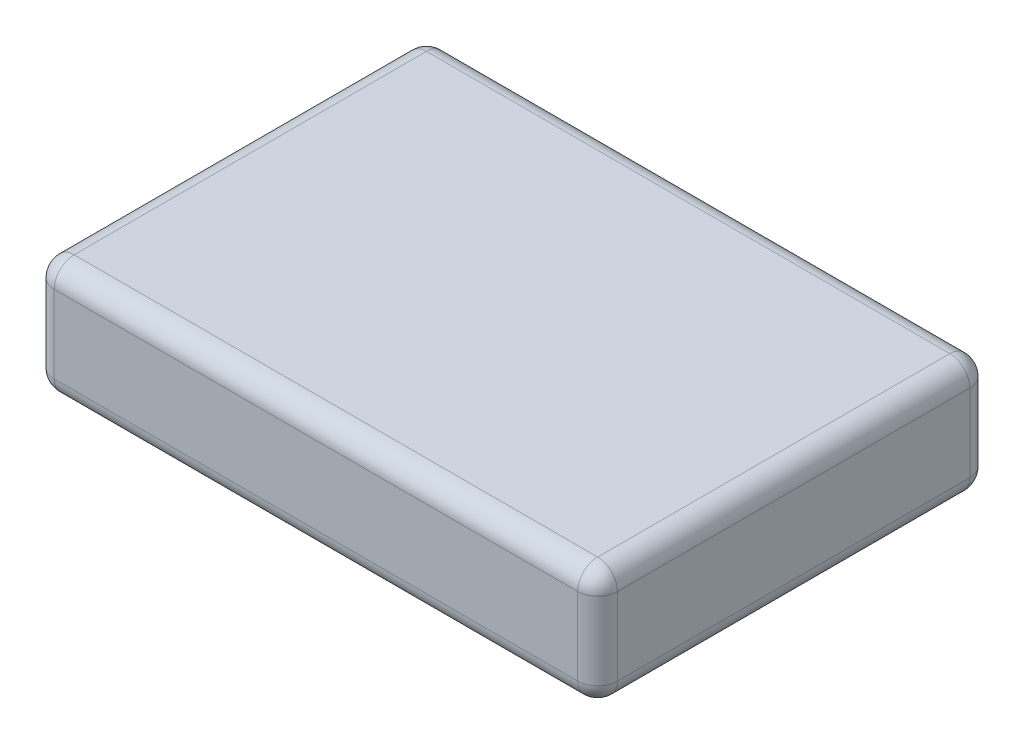
from build123d import *

# Parameters (mm, degrees)
SKETCH1_W           = 71.882
SKETCH1_H           = 50.038
BOSS_EXTRUDE1_DEPTH = 14.986
FILLET1_R           = 2.54


with BuildPart() as part:
    # Sketch1 → Boss-Extrude1 (new body)
    with BuildSketch(Plane(origin=(0, 0, 0), x_dir=(1, 0, 0), z_dir=(0, 1, 0))):
        Rectangle(SKETCH1_W, SKETCH1_H)
    extrude(amount=BOSS_EXTRUDE1_DEPTH)

    # Fillet1
    fillet1_edges = [part.edges().sort_by_distance(p)[0] for p in [
        (35.941, 14.986, 0),
        (0, 14.986, -25.019),
        (-35.941, 14.986, 0),
        (0, 0, -25.019),
        (35.941, 0, 0),
        (0, 0, 25.019),
        (-35.941, 0, 0),
        (-35.941, 7.493, -25.019),
        (35.941, 7.493, -25.019),
        (35.941, 7.493, 25.019),
        (-35.941, 7.493, 25.019),
        (0, 14.986, 25.019),
    ]]
    fillet(fillet1_edges, radius=FILLET1_R)


solid = part.part
